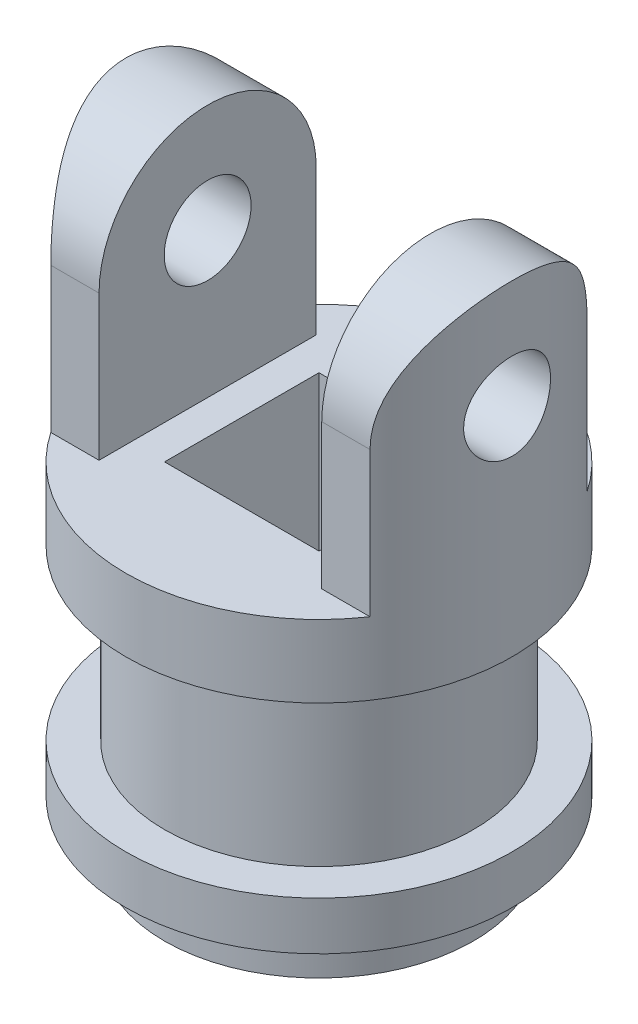
from build123d import *

# Parameters (mm, degrees)
IZIM1_R                     = 32
Y_KSEKLIK_EKSTR_ZYON1_DEPTH = 70
IZIM2_R                     = 40
Y_KSEKLIK_EKSTR_ZYON2_DEPTH = 10
IZIM3_R                     = 40
Y_KSEKLIK_EKSTR_ZYON3_DEPTH = 15
IZIM4_W                     = 32
IZIM4_H                     = 32
KES_EKSTR_ZYON1_DEPTH       = 91
IZIM5_W                     = 10
IZIM5_H                     = 45
Y_KSEKLIK_EKSTR_ZYON6_DEPTH = 52.5
IZIM11_R                    = 9
KES_EKSTR_ZYON2_DEPTH       = 144.472343967
KES_EKSTR_ZYON3_DEPTH       = 144.472344097


with BuildPart() as part:
    # Çizim1 → Yükseklik-Ekstrüzyon1 (new body)
    with BuildSketch(Plane(origin=(0, 0, 0), x_dir=(1, 0, 0), z_dir=(0, 1, 0))):
        with Locations(Location((0, 0, 0), (0, 0, 270))):
            Circle(IZIM1_R)
    extrude(amount=Y_KSEKLIK_EKSTR_ZYON1_DEPTH)

    # Çizim2 → Yükseklik-Ekstrüzyon2 (add)
    with BuildSketch(Plane(origin=(0, 10, 0), x_dir=(1, 0, 0), z_dir=(0, 1, 0))):
        with Locations(Location((0, 0, 0), (0, 0, 270))):
            Circle(IZIM2_R)
    extrude(amount=Y_KSEKLIK_EKSTR_ZYON2_DEPTH)

    # Çizim3 → Yükseklik-Ekstrüzyon3 (add)
    with BuildSketch(Plane(origin=(0, 55, 0), x_dir=(1, 0, 0), z_dir=(0, 1, 0))):
        with Locations(Location((0, 0, 0), (0, 0, 270))):
            Circle(IZIM3_R)
    extrude(amount=Y_KSEKLIK_EKSTR_ZYON3_DEPTH)

    # Çizim4 → Kes-Ekstrüzyon1 (cut, through all)
    with BuildSketch(Plane(origin=(0, 70, 0), x_dir=(1, 0, 0), z_dir=(0, 1, 0))):
        Rectangle(IZIM4_W, IZIM4_H)
    extrude(amount=-KES_EKSTR_ZYON1_DEPTH, mode=Mode.SUBTRACT)

    # Çizim5 → Yükseklik-Ekstrüzyon6 (add)
    with BuildSketch(Plane(origin=(0, 70, 0), x_dir=(1, 0, 0), z_dir=(0, 1, 0))):
        with Locations((-28.071891388, 0)):
            Rectangle(IZIM5_W, IZIM5_H)
        with BuildLine():
            ThreePointArc((-33.071891388, 22.5), (-40, 0), (-33.071891388, -22.5))
            Line((-33.071891388, -22.5), (-33.071891388, 22.5))
        make_face()
        with Locations((28.071891388, 0)):
            Rectangle(IZIM5_W, IZIM5_H)
        with BuildLine():
            Line((33.071891388, 22.5), (33.071891388, -22.5))
            ThreePointArc((33.071891388, -22.5), (38.228756555, -11.771243445), (40, 0))
            ThreePointArc((40, 0), (38.228756555, 11.771243445), (33.071891388, 22.5))
        make_face()
    extrude(amount=Y_KSEKLIK_EKSTR_ZYON6_DEPTH)

    # Çizim11 → Kes-Ekstrüzyon2 (cut, through all)
    with BuildSketch(Plane.ZY.offset(-23.071891388)):
        with Locations((0, 100)):
            Circle(IZIM11_R)
        with BuildLine():
            ThreePointArc((-22.5, 100), (-15.909902516, 115.909902637), (1.71e-07, 122.5))
            Line((1.71e-07, 122.5), (-22.5, 122.5))
            Line((-22.5, 122.5), (-22.5, 100))
        make_face()
        with BuildLine():
            ThreePointArc((1.71e-07, 122.5), (15.909902637, 115.909902516), (22.5, 100))
            Line((22.5, 100), (22.5, 122.5))
            Line((22.5, 122.5), (1.71e-07, 122.5))
        make_face()
    extrude(amount=-KES_EKSTR_ZYON2_DEPTH, mode=Mode.SUBTRACT)

    # Çizim12 → Kes-Ekstrüzyon3 (cut, through all)
    with BuildSketch(Plane(origin=(-23.071891388, 0, 0), x_dir=(0, 0, -1), z_dir=(1, 0, 0))):
        with BuildLine():
            ThreePointArc((-22.5, 100), (-15.90990258, 115.909902574), (-8e-09, 122.5))
            Line((-8e-09, 122.5), (-22.5, 122.5))
            Line((-22.5, 122.5), (-22.5, 100))
        make_face()
        with BuildLine():
            ThreePointArc((-9, 100), (0, 91), (9, 100))
            Line((9, 100), (-9, 100))
        make_face()
        with BuildLine():
            Line((-9, 100), (9, 100))
            ThreePointArc((9, 100), (0, 109), (-9, 100))
        make_face()
        with BuildLine():
            ThreePointArc((-8e-09, 122.5), (15.909902574, 115.90990258), (22.5, 100))
            Line((22.5, 100), (22.5, 122.5))
            Line((22.5, 122.5), (-8e-09, 122.5))
        make_face()
    extrude(amount=-KES_EKSTR_ZYON3_DEPTH, mode=Mode.SUBTRACT)


solid = part.part
